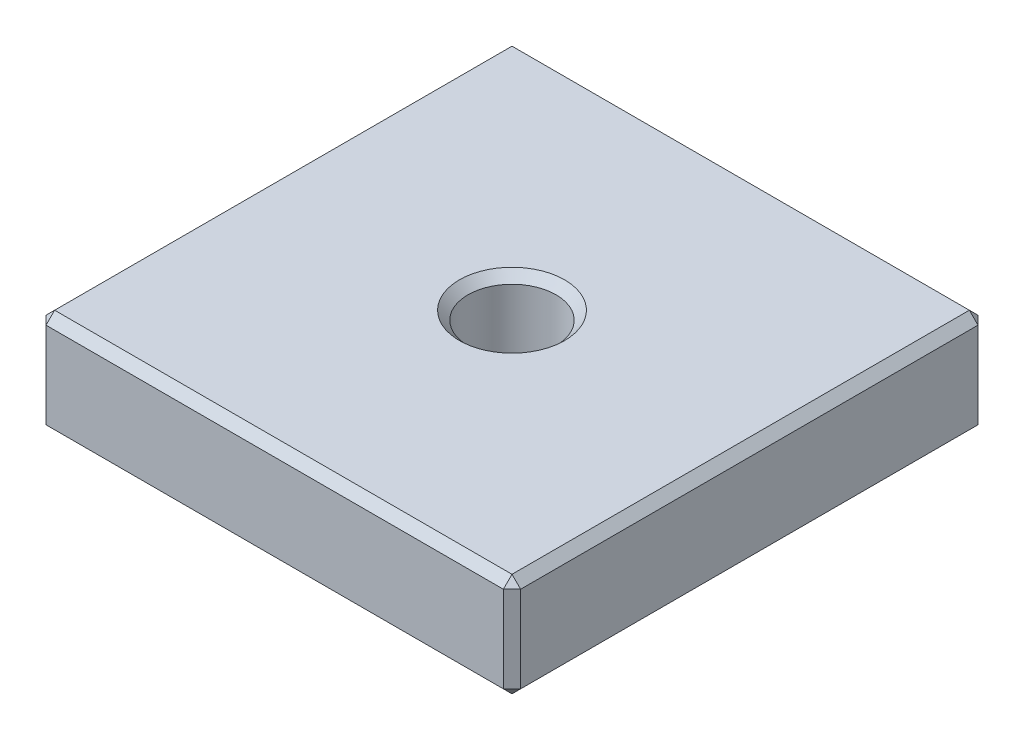
from build123d import *

# Parameters (mm, degrees)
ESQUISSE1_W        = 55
ESQUISSE1_H        = 55
BOSS_EXTRU_1_DEPTH = 12
TROU_TARAUD_M121_D = 10.2
CHANFREIN1_SIZE    = 1


with BuildPart() as part:
    # Esquisse1 → Boss.-Extru.1 (new body)
    with BuildSketch(Plane(origin=(0, 0, 0), x_dir=(1, 0, 0), z_dir=(0, 1, 0))):
        with Locations((27.5, 27.5)):
            Rectangle(ESQUISSE1_W, ESQUISSE1_H)
    extrude(amount=BOSS_EXTRU_1_DEPTH)

    # Trou taraudé M121 (through all)
    with Locations(Plane.XZ):
        with Locations((27.5, -27.5)):
            Hole(TROU_TARAUD_M121_D / 2)

    # Chanfrein1
    chanfrein1_edges = [part.edges().sort_by_distance(p)[0] for p in [
        (55, 12, -27.5),
        (27.5, 12, -55),
        (32.6, 0, -27.5),
        (32.6, 12, -27.5),
        (0, 12, -27.5),
        (27.5, 0, -55),
        (55, 0, -27.5),
        (27.5, 0, 0),
        (0, 0, -27.5),
        (27.5, 12, 0),
        (0, 6, -55),
        (55, 6, -55),
        (55, 6, 0),
        (0, 6, 0),
    ]]
    chamfer(chanfrein1_edges, length=CHANFREIN1_SIZE)


solid = part.part
